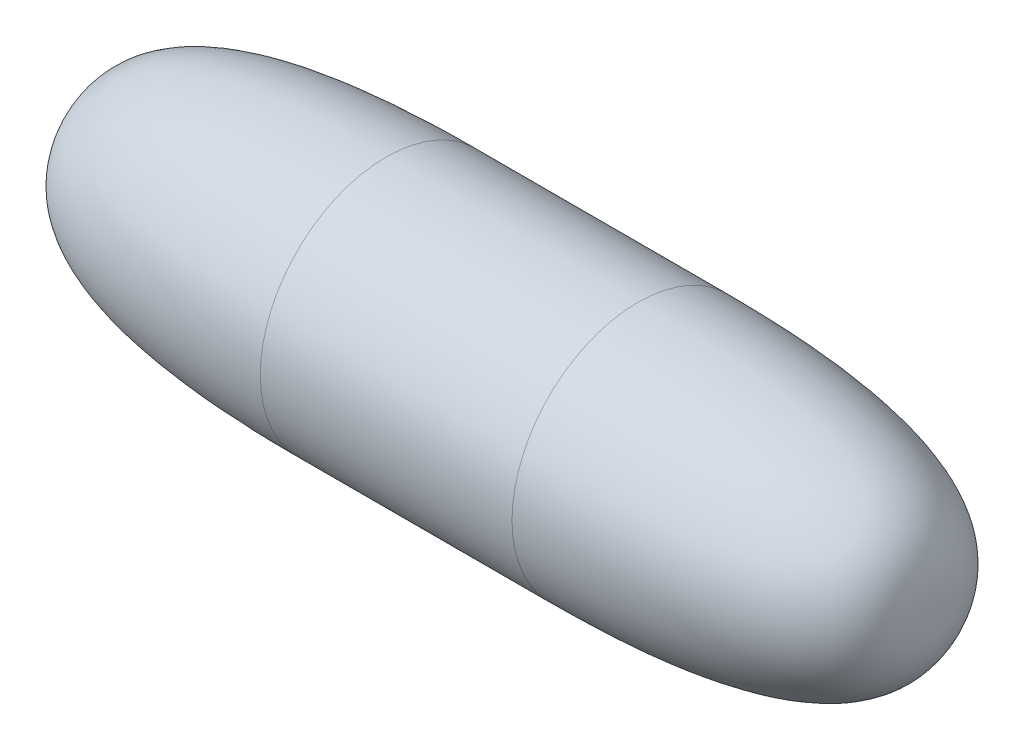
from build123d import *


with BuildPart() as part:
    # Sketch1 → Revolve1 (revolve)
    with BuildSketch(Plane.XY):
        with BuildLine():
            Line((0, 0), (63.5, 0))
            add(Edge.make_bspline(
                [(19.05, 19.05), (63.908779388, 19.05), (63.5, 6.92198844), (63.5, 0)],
                knots=[0, 0, 0, 0, 1, 1, 1, 1], degree=3))
            Line((19.05, 19.05), (0, 19.05))
            Line((0, 19.05), (0, 0))
        make_face()
    revolve1 = revolve(axis=Axis((0, 0, 0), (1, 0, 0)))

    # Mirror1: Revolve1 across plane
    add(revolve1.mirror(Plane(origin=(0, 19.05, 0), x_dir=(0, 0, 1), z_dir=(1, 0, 0))))


solid = part.part
